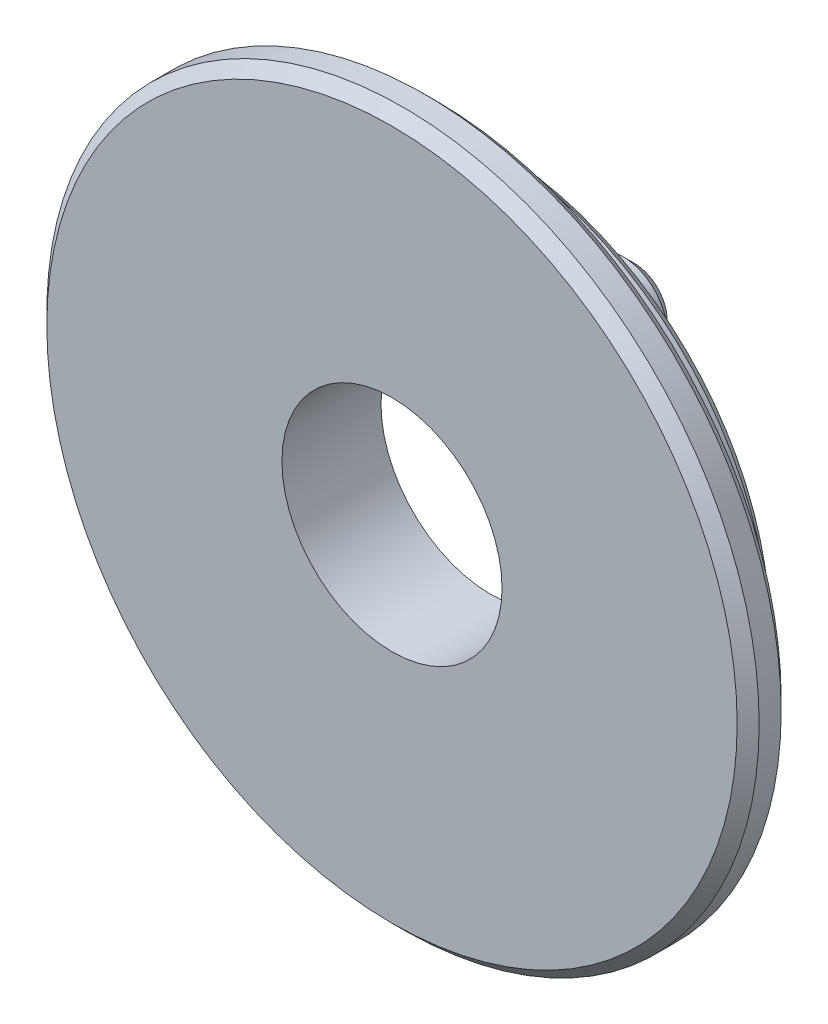
from build123d import *

# Parameters (mm, degrees)
M6X1_0_TAPPED_HOLE1_D     = 5
M6X1_0_TAPPED_HOLE1_DEPTH = 15
M6X1_0_TAPPED_HOLE1_TIP   = 1.502151548
SKETCH3_R                 = 1
EXTRUDE1_DEPTH            = 1
CHAMFER1_SIZE             = 0.25


with BuildPart() as part:
    # Sketch1 → Revolve1 (revolve)
    with BuildSketch(Plane(origin=(0, 0, 0), x_dir=(1, 0, 0), z_dir=(0, 1, 0))):
        Polygon((0, 0), (0, 2.25), (6.58, 2.25), (6.58, 1), (8.09, 1), (8.09, 0), align=None)
    revolve(axis=Axis((0, 0, 17.872516556), (0, 0, -1)))

    # M6x1.0 Tapped Hole1
    with Locations(Plane.XY):
        with Locations((0, 0)):
            Hole(M6X1_0_TAPPED_HOLE1_D / 2, depth=M6X1_0_TAPPED_HOLE1_DEPTH)
            with Locations((0, 0, -(M6X1_0_TAPPED_HOLE1_DEPTH + M6X1_0_TAPPED_HOLE1_TIP / 2))):  # 118° drill point
                Cone(0, M6X1_0_TAPPED_HOLE1_D / 2, M6X1_0_TAPPED_HOLE1_TIP, mode=Mode.SUBTRACT)

    # Sketch3 → Extrude1 (add)
    with BuildSketch(Plane(origin=(0, 0, -2.25), x_dir=(-1, 0, 0), z_dir=(0, 0, -1))):
        with Locations((4.5, 0)):
            Circle(SKETCH3_R)
        with Locations(Location((-2.25, 3.897114317, 0), (0, 0, 180))):  # turned: the seam where the file's is
            Circle(SKETCH3_R)
        with Locations((-2.25, -3.897114317)):
            Circle(SKETCH3_R)
    extrude(amount=EXTRUDE1_DEPTH)

    # Chamfer1
    chamfer1_edges = [part.edges().sort_by_distance(p)[0] for p in [
        (-3.5, 0, -3.25),
        (1.25, 3.897114317, -3.25),
        (3.25, -3.897114317, -3.25),
        (-8.09, 0, 0),
        (-6.58, 0, -2.25),
        (-8.09, 0, -1),
    ]]
    chamfer(chamfer1_edges, length=CHAMFER1_SIZE)


solid = part.part
